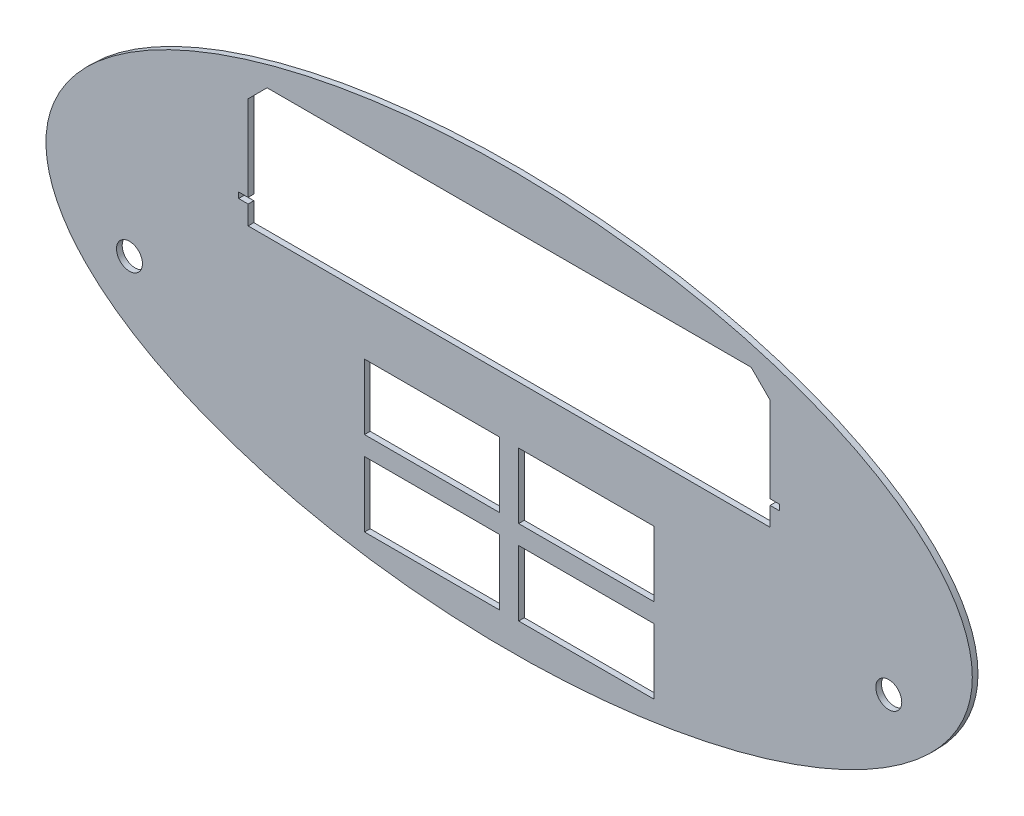
from build123d import *

# Parameters (mm, degrees)
SKETCH1_RX          = 244
SKETCH1_RY          = 110
BOSS_EXTRUDE1_DEPTH = 3
CUT_EXTRUDE5_DEPTH  = 4
SKETCH13_W          = 71.2
SKETCH13_H          = 34.45
CUT_EXTRUDE7_DEPTH  = 4
SKETCH12_R          = 6.83635542
CUT_EXTRUDE8_DEPTH  = 4
CHAMFER1_SIZE       = 10


with BuildPart() as part:
    # Sketch1 → Boss-Extrude1 (new body)
    with BuildSketch(Plane.XY):
        with Locations((0, 0)):
            Ellipse(SKETCH1_RX, SKETCH1_RY)
    extrude(amount=-BOSS_EXTRUDE1_DEPTH)

    # Sketch10 → Cut-Extrude5 (cut, through all)
    with BuildSketch(Plane.XY):
        Polygon((-137.5, 83.1), (137.5, 83.1), (137.5, 28.1), (142.5, 28.1), (142.5, 25.1), (137.5, 25.1), (137.5, 15.1), (-137.5, 15.1), (-137.5, 25.1), (-142.5, 25.1), (-142.5, 28.1), (-137.5, 28.1), align=None)
    extrude(amount=-CUT_EXTRUDE5_DEPTH, mode=Mode.SUBTRACT)

    # Sketch13 → Cut-Extrude7 (cut, through all)
    with BuildSketch(Plane.XY):
        with Locations((-40.6, -32.225)):
            Rectangle(SKETCH13_W, SKETCH13_H)
        with Locations((-40.6, -76.675)):
            Rectangle(SKETCH13_W, SKETCH13_H)
        with Locations((40.6, -32.225)):
            Rectangle(SKETCH13_W, SKETCH13_H)
        with Locations((40.6, -76.675)):
            Rectangle(SKETCH13_W, SKETCH13_H)
    extrude(amount=-CUT_EXTRUDE7_DEPTH, mode=Mode.SUBTRACT)

    # Sketch12 → Cut-Extrude8 (cut, through all)
    with BuildSketch(Plane.XY):
        with Locations((200, -30)):
            Circle(SKETCH12_R)
        with Locations((-200, -30)):
            Circle(SKETCH12_R)
    extrude(amount=-CUT_EXTRUDE8_DEPTH, mode=Mode.SUBTRACT)

    # Chamfer1
    chamfer1_edges = [part.edges().sort_by_distance(p)[0] for p in [
        (-137.5, 83.1, -1.5),
        (137.5, 83.1, -1.5),
    ]]
    chamfer(chamfer1_edges, length=CHAMFER1_SIZE)


solid = part.part
